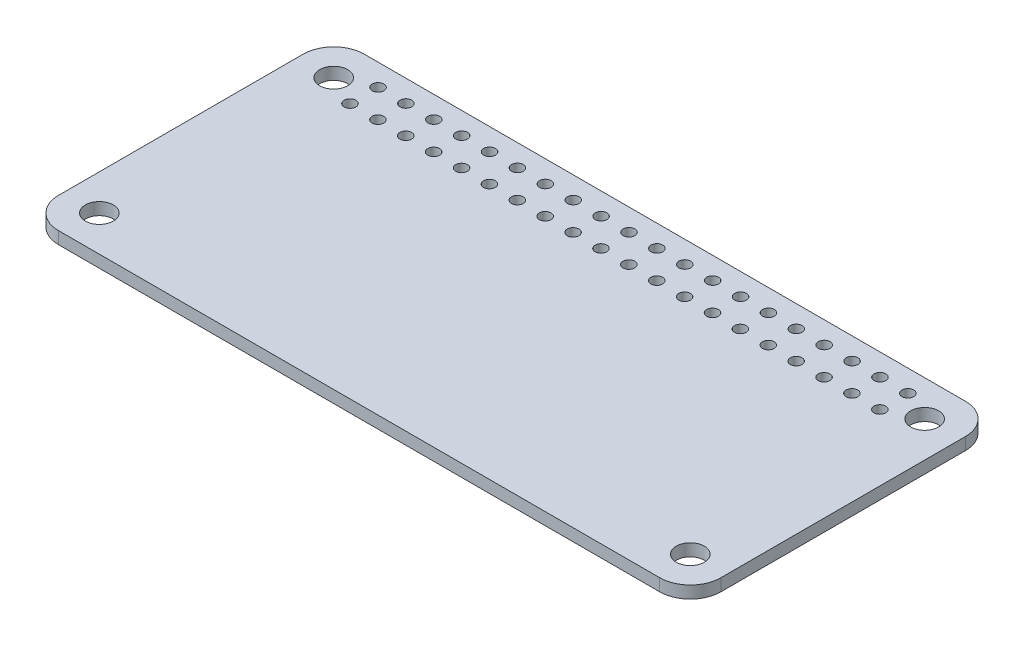
from build123d import *

# Parameters (mm, degrees)
SKETCH1_R           = 0.575
SKETCH1_R_2         = 1.375
BOSS_EXTRUDE1_DEPTH = 1.2


with BuildPart() as part:
    # Sketch1 → Boss-Extrude1 (new body)
    with BuildSketch(Plane(origin=(0, 0, 0), x_dir=(1, 0, 0), z_dir=(0, 1, 0))):
        with BuildLine():
            Line((3, 0), (62, 0))
            ThreePointArc((62, 0), (64.121320344, 0.878679656), (65, 3))
            Line((65, 3), (65, 27))
            ThreePointArc((65, 27), (64.121320344, 29.121320344), (62, 30))
            Line((62, 30), (3, 30))
            ThreePointArc((3, 30), (0.878679656, 29.121320344), (0, 27))
            Line((0, 27), (0, 3))
            ThreePointArc((0, 3), (0.878679656, 0.878679656), (3, 0))
        make_face()
        with Locations((6.5, 27.85)):
            Circle(SKETCH1_R, mode=Mode.SUBTRACT)
        with Locations((9.236842105, 27.85)):
            Circle(SKETCH1_R, mode=Mode.SUBTRACT)
        with Locations((11.973684211, 27.85)):
            Circle(SKETCH1_R, mode=Mode.SUBTRACT)
        with Locations((14.710526316, 27.85)):
            Circle(SKETCH1_R, mode=Mode.SUBTRACT)
        with Locations((17.447368421, 27.85)):
            Circle(SKETCH1_R, mode=Mode.SUBTRACT)
        with Locations((20.184210526, 27.85)):
            Circle(SKETCH1_R, mode=Mode.SUBTRACT)
        with Locations((22.921052632, 27.85)):
            Circle(SKETCH1_R, mode=Mode.SUBTRACT)
        with Locations((25.657894737, 27.85)):
            Circle(SKETCH1_R, mode=Mode.SUBTRACT)
        with Locations((28.394736842, 27.85)):
            Circle(SKETCH1_R, mode=Mode.SUBTRACT)
        with Locations((31.131578947, 27.85)):
            Circle(SKETCH1_R, mode=Mode.SUBTRACT)
        with Locations((33.868421053, 27.85)):
            Circle(SKETCH1_R, mode=Mode.SUBTRACT)
        with Locations((36.605263158, 27.85)):
            Circle(SKETCH1_R, mode=Mode.SUBTRACT)
        with Locations((39.342105263, 27.85)):
            Circle(SKETCH1_R, mode=Mode.SUBTRACT)
        with Locations((42.078947368, 27.85)):
            Circle(SKETCH1_R, mode=Mode.SUBTRACT)
        with Locations((44.815789474, 27.85)):
            Circle(SKETCH1_R, mode=Mode.SUBTRACT)
        with Locations((47.552631579, 27.85)):
            Circle(SKETCH1_R, mode=Mode.SUBTRACT)
        with Locations((50.289473684, 27.85)):
            Circle(SKETCH1_R, mode=Mode.SUBTRACT)
        with Locations((53.026315789, 27.85)):
            Circle(SKETCH1_R, mode=Mode.SUBTRACT)
        with Locations((55.763157895, 27.85)):
            Circle(SKETCH1_R, mode=Mode.SUBTRACT)
        with Locations((58.5, 27.85)):
            Circle(SKETCH1_R, mode=Mode.SUBTRACT)
        with Locations((9.236842105, 25.1)):
            Circle(SKETCH1_R, mode=Mode.SUBTRACT)
        with Locations((11.973684211, 25.1)):
            Circle(SKETCH1_R, mode=Mode.SUBTRACT)
        with Locations((14.710526316, 25.1)):
            Circle(SKETCH1_R, mode=Mode.SUBTRACT)
        with Locations((17.447368421, 25.1)):
            Circle(SKETCH1_R, mode=Mode.SUBTRACT)
        with Locations((20.184210526, 25.1)):
            Circle(SKETCH1_R, mode=Mode.SUBTRACT)
        with Locations((22.921052632, 25.1)):
            Circle(SKETCH1_R, mode=Mode.SUBTRACT)
        with Locations((25.657894737, 25.1)):
            Circle(SKETCH1_R, mode=Mode.SUBTRACT)
        with Locations((28.394736842, 25.1)):
            Circle(SKETCH1_R, mode=Mode.SUBTRACT)
        with Locations((31.131578947, 25.1)):
            Circle(SKETCH1_R, mode=Mode.SUBTRACT)
        with Locations((33.868421053, 25.1)):
            Circle(SKETCH1_R, mode=Mode.SUBTRACT)
        with Locations((36.605263158, 25.1)):
            Circle(SKETCH1_R, mode=Mode.SUBTRACT)
        with Locations((39.342105263, 25.1)):
            Circle(SKETCH1_R, mode=Mode.SUBTRACT)
        with Locations((42.078947368, 25.1)):
            Circle(SKETCH1_R, mode=Mode.SUBTRACT)
        with Locations((44.815789474, 25.1)):
            Circle(SKETCH1_R, mode=Mode.SUBTRACT)
        with Locations((47.552631579, 25.1)):
            Circle(SKETCH1_R, mode=Mode.SUBTRACT)
        with Locations((50.289473684, 25.1)):
            Circle(SKETCH1_R, mode=Mode.SUBTRACT)
        with Locations((53.026315789, 25.1)):
            Circle(SKETCH1_R, mode=Mode.SUBTRACT)
        with Locations((55.763157895, 25.1)):
            Circle(SKETCH1_R, mode=Mode.SUBTRACT)
        with Locations((58.5, 25.1)):
            Circle(SKETCH1_R, mode=Mode.SUBTRACT)
        with Locations((6.5, 25.1)):
            Circle(SKETCH1_R, mode=Mode.SUBTRACT)
        with Locations((3.5, 26.5)):
            Circle(SKETCH1_R_2, mode=Mode.SUBTRACT)
        with Locations((61.5, 26.5)):
            Circle(SKETCH1_R_2, mode=Mode.SUBTRACT)
        with Locations((61.5, 3.5)):
            Circle(SKETCH1_R_2, mode=Mode.SUBTRACT)
        with Locations((3.5, 3.5)):
            Circle(SKETCH1_R_2, mode=Mode.SUBTRACT)
    extrude(amount=BOSS_EXTRUDE1_DEPTH)


solid = part.part
